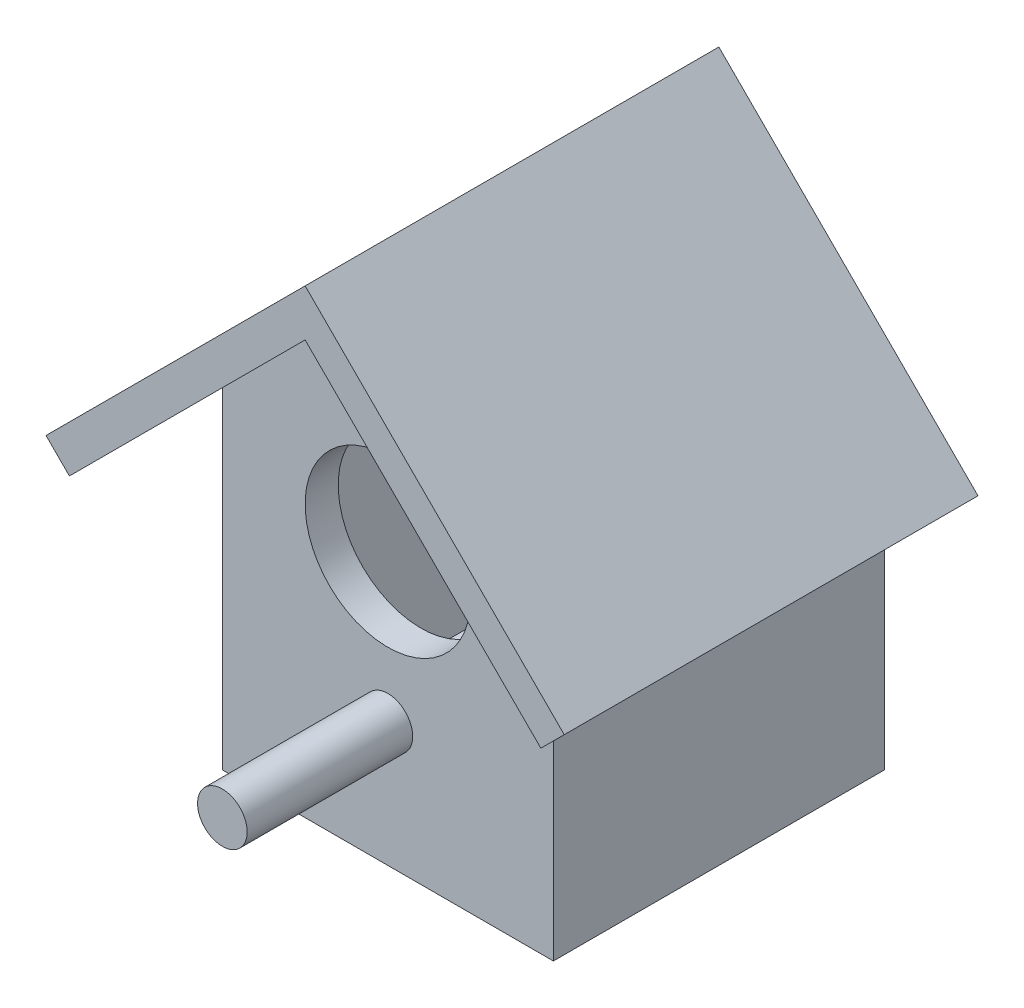
from build123d import *

# Parameters (mm, degrees)
SKETCH1_R                = 15
SKETCH1_R_2              = 50
BOSS_EXTRUDE1_DEPTH      = 20
BOSS_EXTRUDE2_DEPTH      = 200
BOSS_EXTRUDE4_START      = 180
SKETCH1_7_R              = 15
SKETCH1_7_R_2            = 50
BOSS_EXTRUDE4_DEPTH      = 20
BOSS_EXTRUDE5_DEPTH      = 250
BOSS_EXTRUDE6_START      = 200
SKETCH1_9_R              = 15
BOSS_EXTRUDE6_DEPTH      = 100
BOSS_EXTRUDE6_DEPTH_BACK = 20


with BuildPart() as part:
    # Sketch1 → Boss-Extrude1 (new body)
    with BuildSketch(Plane.XY):
        Polygon((100, 300), (20, 220), (20, 20), (180, 20), (180, 220), align=None)
        with Locations((100, 75)):
            Circle(SKETCH1_R, mode=Mode.SUBTRACT)
        with Locations((100, 164.142135624)):
            Circle(SKETCH1_R_2, mode=Mode.SUBTRACT)
        with Locations((100, 75)):
            Circle(SKETCH1_R)
        with Locations((100, 164.142135624)):
            Circle(SKETCH1_R_2)
    extrude(amount=BOSS_EXTRUDE1_DEPTH)

    # Sketch1_5 → Boss-Extrude2 (add)
    with BuildSketch(Plane.XY):
        Polygon((0, 200), (0, 0), (200, 0), (200, 200), (180, 220), (180, 20), (20, 20), (20, 220), align=None)
    extrude(amount=BOSS_EXTRUDE2_DEPTH)

    # Sketch1_7 → Boss-Extrude4 (add)
    with BuildSketch(Plane.XY.offset(BOSS_EXTRUDE4_START)):
        Polygon((100, 300), (20, 220), (20, 20), (180, 20), (180, 220), align=None)
        with Locations((100, 75)):
            Circle(SKETCH1_7_R, mode=Mode.SUBTRACT)
        with Locations((100, 164.142135624)):
            Circle(SKETCH1_7_R_2, mode=Mode.SUBTRACT)
    extrude(amount=BOSS_EXTRUDE4_DEPTH)

    # Sketch1_8 → Boss-Extrude5 (add)
    with BuildSketch(Plane.XY):
        Polygon((0, 200), (100, 300), (200, 200), (242.426406871, 157.573593129), (256.568542495, 171.715728753), (100, 328.284271247), (-56.568542495, 171.715728753), (-42.426406871, 157.573593129), align=None)
    extrude(amount=BOSS_EXTRUDE5_DEPTH)


with BuildPart() as body_2:
    # Sketch1_9 → Boss-Extrude6 (new body, two sides)
    with BuildSketch(Plane.XY.offset(BOSS_EXTRUDE6_START)) as boss_extrude6_sk:
        with Locations((100, 75)):
            Circle(SKETCH1_9_R)
    extrude(amount=BOSS_EXTRUDE6_DEPTH)
    extrude(boss_extrude6_sk.sketch, amount=-BOSS_EXTRUDE6_DEPTH_BACK)


solid = Compound([part.part, body_2.part])
